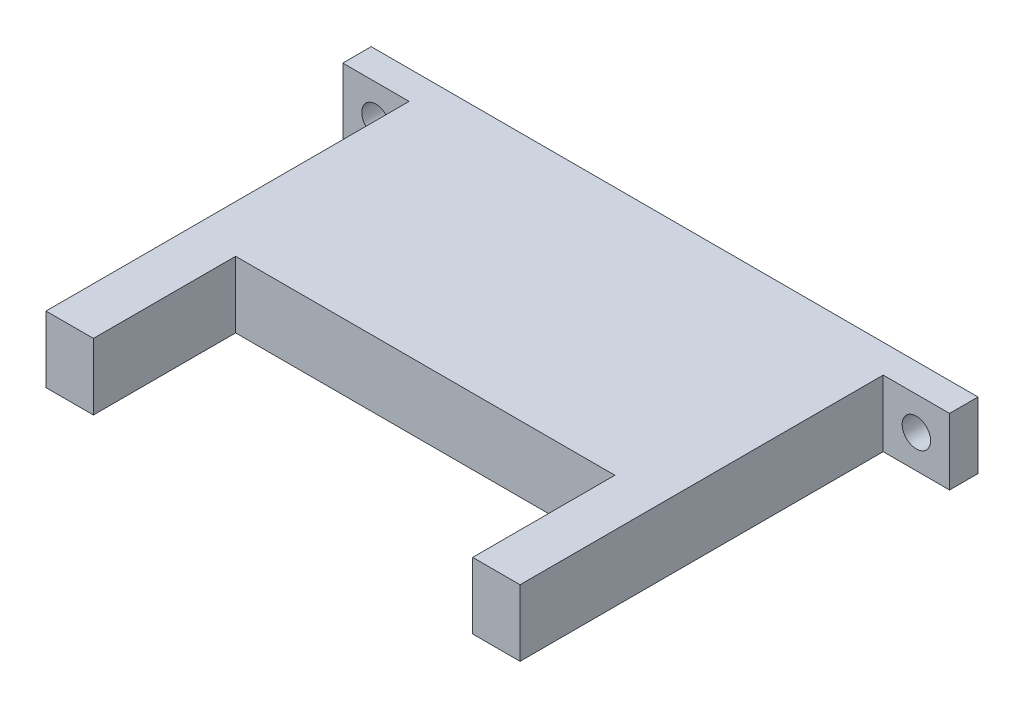
from build123d import *

# Parameters (mm, degrees)
SKETCH_1_W          = 64
SKETCH_1_H          = 7
EXTRUDE_3_DEPTH     = 3
SKETCH_3_W          = 50
SKETCH_3_H          = 7
EXTRUDE_4_DEPTH     = 23.3
SKETCH_4_W          = 5
SKETCH_4_H          = 7
EXTRUDE_5_DEPTH     = 15
SKETCH_5_W          = 5
SKETCH_5_H          = 7
EXTRUDE_6_DEPTH     = 15
SKETCH_6_R          = 1.5
CUT_EXTRUDE_1_DEPTH = 3
SKETCH_7_R          = 1.5
CUT_EXTRUDE_2_DEPTH = 3


with BuildPart() as part:
    # Эскиз1 → Бобышка-Вытянуть3 (new body)
    with BuildSketch(Plane.XY):
        Rectangle(SKETCH_1_W, SKETCH_1_H)
    extrude(amount=EXTRUDE_3_DEPTH)

    # Эскиз3 → Бобышка-Вытянуть4 (add)
    with BuildSketch(Plane.XY.offset(3)):
        Rectangle(SKETCH_3_W, SKETCH_3_H)
    extrude(amount=EXTRUDE_4_DEPTH)

    # Эскиз4 → Бобышка-Вытянуть5 (add)
    with BuildSketch(Plane.XY.offset(26.3)):
        with Locations((-22.5, 0)):
            Rectangle(SKETCH_4_W, SKETCH_4_H)
    extrude(amount=EXTRUDE_5_DEPTH)

    # Эскиз5 → Бобышка-Вытянуть6 (add)
    with BuildSketch(Plane.XY.offset(26.3)):
        with Locations((22.5, 0)):
            Rectangle(SKETCH_5_W, SKETCH_5_H)
    extrude(amount=EXTRUDE_6_DEPTH)

    # Эскиз6 → Вырез-Вытянуть1 (cut)
    with BuildSketch(Plane.XY.offset(3)):
        with Locations((-28.5, 0)):
            Circle(SKETCH_6_R)
    extrude(amount=-CUT_EXTRUDE_1_DEPTH, mode=Mode.SUBTRACT)

    # Эскиз7 → Вырез-Вытянуть2 (cut)
    with BuildSketch(Plane.XY.offset(3)):
        with Locations((28.5, 0)):
            Circle(SKETCH_7_R)
    extrude(amount=-CUT_EXTRUDE_2_DEPTH, mode=Mode.SUBTRACT)


solid = part.part
